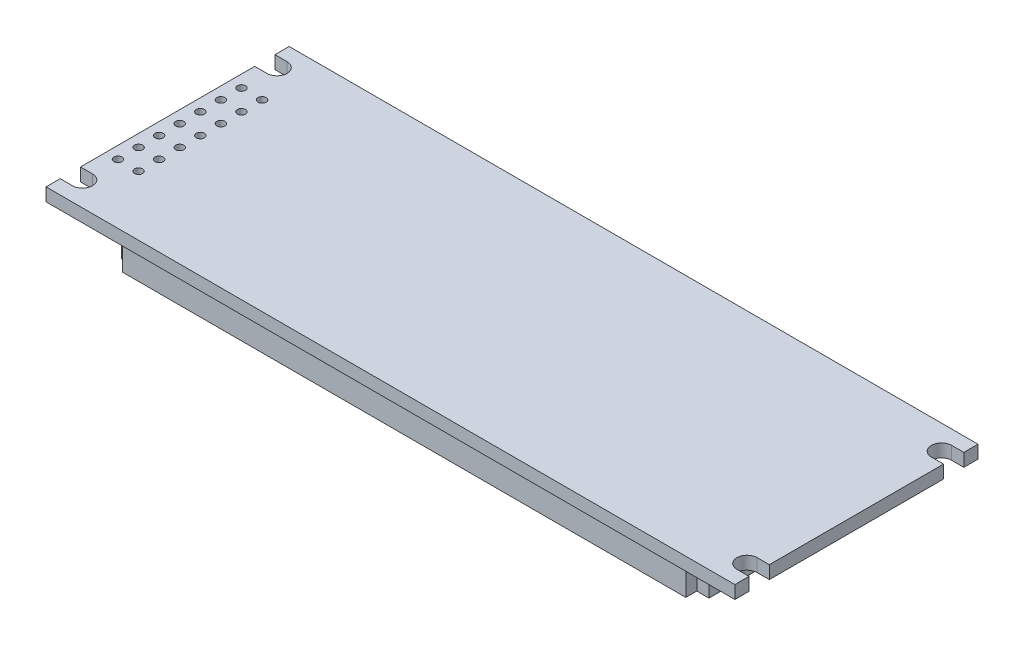
from build123d import *

# Parameters (mm, degrees)
BOSS_EXTRU_1_DEPTH      = 1.6
ESQUISSE2_R             = 0.5
ENL_V_MAT_EXTRU_1_DEPTH = 2.6
BOSS_EXTRU_2_DEPTH      = 4.5
ESQUISSE5_W             = 62
ESQUISSE5_H             = 16
ENL_V_MAT_EXTRU_2_DEPTH = 0.2
ESQUISSE6_W             = 2.78
ESQUISSE6_H             = 4.89
ENL_V_MAT_EXTRU_3_DEPTH = 0.1


with BuildPart() as part:
    # Esquisse1 → Boss.-Extru.1 (new body)
    with BuildSketch(Plane(origin=(0, 0, 0), x_dir=(1, 0, 0), z_dir=(0, 1, 0))):
        with BuildLine():
            Line((-41, -13.25), (-42.5, -13.25))
            Line((-42.5, -13.25), (-42.5, -15))
            Line((-42.5, -15), (42.5, -15))
            Line((42.5, -15), (42.5, -13.25))
            Line((42.5, -13.25), (41, -13.25))
            ThreePointArc((41, -13.25), (39.75, -12), (41, -10.75))
            Line((41, -10.75), (42.5, -10.75))
            Line((42.5, -10.75), (42.5, 10.75))
            Line((42.5, 10.75), (41, 10.75))
            ThreePointArc((41, 10.75), (39.75, 12), (41, 13.25))
            Line((41, 13.25), (42.5, 13.25))
            Line((42.5, 13.25), (42.5, 15))
            Line((42.5, 15), (-42.5, 15))
            Line((-42.5, 15), (-42.5, 13.25))
            Line((-42.5, 13.25), (-41, 13.25))
            ThreePointArc((-41, 13.25), (-39.75, 12), (-41, 10.75))
            Line((-41, 10.75), (-42.5, 10.75))
            Line((-42.5, 10.75), (-42.5, -10.75))
            Line((-42.5, -10.75), (-41, -10.75))
            ThreePointArc((-41, -10.75), (-39.75, -12), (-41, -13.25))
        make_face()
    extrude(amount=BOSS_EXTRU_1_DEPTH)

    # Esquisse2 → Enlèv. mat.-Extru.1 (cut, through all)
    with BuildSketch(Plane.XZ):
        with Locations((-41, 7.62)):
            Circle(ESQUISSE2_R)
        with Locations((-38.46, 7.62)):
            Circle(ESQUISSE2_R)
        with Locations((-38.46, 5.08)):
            Circle(ESQUISSE2_R)
        with Locations((-38.46, 2.54)):
            Circle(ESQUISSE2_R)
        with Locations((-38.46, 0)):
            Circle(ESQUISSE2_R)
        with Locations((-38.46, -2.54)):
            Circle(ESQUISSE2_R)
        with Locations((-38.46, -5.08)):
            Circle(ESQUISSE2_R)
        with Locations((-38.46, -7.62)):
            Circle(ESQUISSE2_R)
        with Locations((-41, 5.08)):
            Circle(ESQUISSE2_R)
        with Locations((-41, 2.54)):
            Circle(ESQUISSE2_R)
        with Locations((-41, 0)):
            Circle(ESQUISSE2_R)
        with Locations((-41, -2.54)):
            Circle(ESQUISSE2_R)
        with Locations((-41, -5.08)):
            Circle(ESQUISSE2_R)
        with Locations((-41, -7.62)):
            Circle(ESQUISSE2_R)
    extrude(amount=-ENL_V_MAT_EXTRU_1_DEPTH, mode=Mode.SUBTRACT)

    # Esquisse3 → Boss.-Extru.2 (add)
    with BuildSketch(Plane.XZ):
        Polygon((-34.75, 13.3), (-34.75, 11.95), (-36.25, 11.95), (-36.25, -11.95), (-34.75, -11.95), (-34.75, -13.3), (34.75, -13.3), (34.75, -11.95), (36.25, -11.95), (36.25, 11.95), (34.75, 11.95), (34.75, 13.3), align=None)
    extrude(amount=BOSS_EXTRU_2_DEPTH)

    # Esquisse5 → Enlèv. mat.-Extru.2 (cut)
    with BuildSketch(Plane.XZ.offset(4.5)):
        Rectangle(ESQUISSE5_W, ESQUISSE5_H)
    extrude(amount=-ENL_V_MAT_EXTRU_2_DEPTH, mode=Mode.SUBTRACT)

    # Esquisse6 → Enlèv. mat.-Extru.3 (cut)
    with BuildSketch(Plane.XZ.offset(4.3)):
        with Locations((26.475, -3.045)):
            Rectangle(ESQUISSE6_W, ESQUISSE6_H)
        with Locations((22.995, -3.045)):
            Rectangle(ESQUISSE6_W, ESQUISSE6_H)
        with Locations((19.515, -3.045)):
            Rectangle(ESQUISSE6_W, ESQUISSE6_H)
        with Locations((16.035, -3.045)):
            Rectangle(ESQUISSE6_W, ESQUISSE6_H)
        with Locations((12.555, -3.045)):
            Rectangle(ESQUISSE6_W, ESQUISSE6_H)
        with Locations((9.075, -3.045)):
            Rectangle(ESQUISSE6_W, ESQUISSE6_H)
        with Locations((5.595, -3.045)):
            Rectangle(ESQUISSE6_W, ESQUISSE6_H)
        with Locations((2.115, -3.045)):
            Rectangle(ESQUISSE6_W, ESQUISSE6_H)
        with Locations((-1.365, -3.045)):
            Rectangle(ESQUISSE6_W, ESQUISSE6_H)
        with Locations((-4.845, -3.045)):
            Rectangle(ESQUISSE6_W, ESQUISSE6_H)
        with Locations((-8.325, -3.045)):
            Rectangle(ESQUISSE6_W, ESQUISSE6_H)
        with Locations((-11.805, -3.045)):
            Rectangle(ESQUISSE6_W, ESQUISSE6_H)
        with Locations((-15.285, -3.045)):
            Rectangle(ESQUISSE6_W, ESQUISSE6_H)
        with Locations((-18.765, -3.045)):
            Rectangle(ESQUISSE6_W, ESQUISSE6_H)
        with Locations((-22.245, -3.045)):
            Rectangle(ESQUISSE6_W, ESQUISSE6_H)
        with Locations((-25.725, -3.045)):
            Rectangle(ESQUISSE6_W, ESQUISSE6_H)
        with Locations((26.475, 2.955)):
            Rectangle(ESQUISSE6_W, ESQUISSE6_H)
        with Locations((22.995, 2.955)):
            Rectangle(ESQUISSE6_W, ESQUISSE6_H)
        with Locations((19.515, 2.955)):
            Rectangle(ESQUISSE6_W, ESQUISSE6_H)
        with Locations((16.035, 2.955)):
            Rectangle(ESQUISSE6_W, ESQUISSE6_H)
        with Locations((12.555, 2.955)):
            Rectangle(ESQUISSE6_W, ESQUISSE6_H)
        with Locations((9.075, 2.955)):
            Rectangle(ESQUISSE6_W, ESQUISSE6_H)
        with Locations((5.595, 2.955)):
            Rectangle(ESQUISSE6_W, ESQUISSE6_H)
        with Locations((2.115, 2.955)):
            Rectangle(ESQUISSE6_W, ESQUISSE6_H)
        with Locations((-1.365, 2.955)):
            Rectangle(ESQUISSE6_W, ESQUISSE6_H)
        with Locations((-4.845, 2.955)):
            Rectangle(ESQUISSE6_W, ESQUISSE6_H)
        with Locations((-8.325, 2.955)):
            Rectangle(ESQUISSE6_W, ESQUISSE6_H)
        with Locations((-11.805, 2.955)):
            Rectangle(ESQUISSE6_W, ESQUISSE6_H)
        with Locations((-15.285, 2.955)):
            Rectangle(ESQUISSE6_W, ESQUISSE6_H)
        with Locations((-18.765, 2.955)):
            Rectangle(ESQUISSE6_W, ESQUISSE6_H)
        with Locations((-22.245, 2.955)):
            Rectangle(ESQUISSE6_W, ESQUISSE6_H)
        with Locations((-25.725, 2.955)):
            Rectangle(ESQUISSE6_W, ESQUISSE6_H)
    extrude(amount=-ENL_V_MAT_EXTRU_3_DEPTH, mode=Mode.SUBTRACT)


solid = part.part
